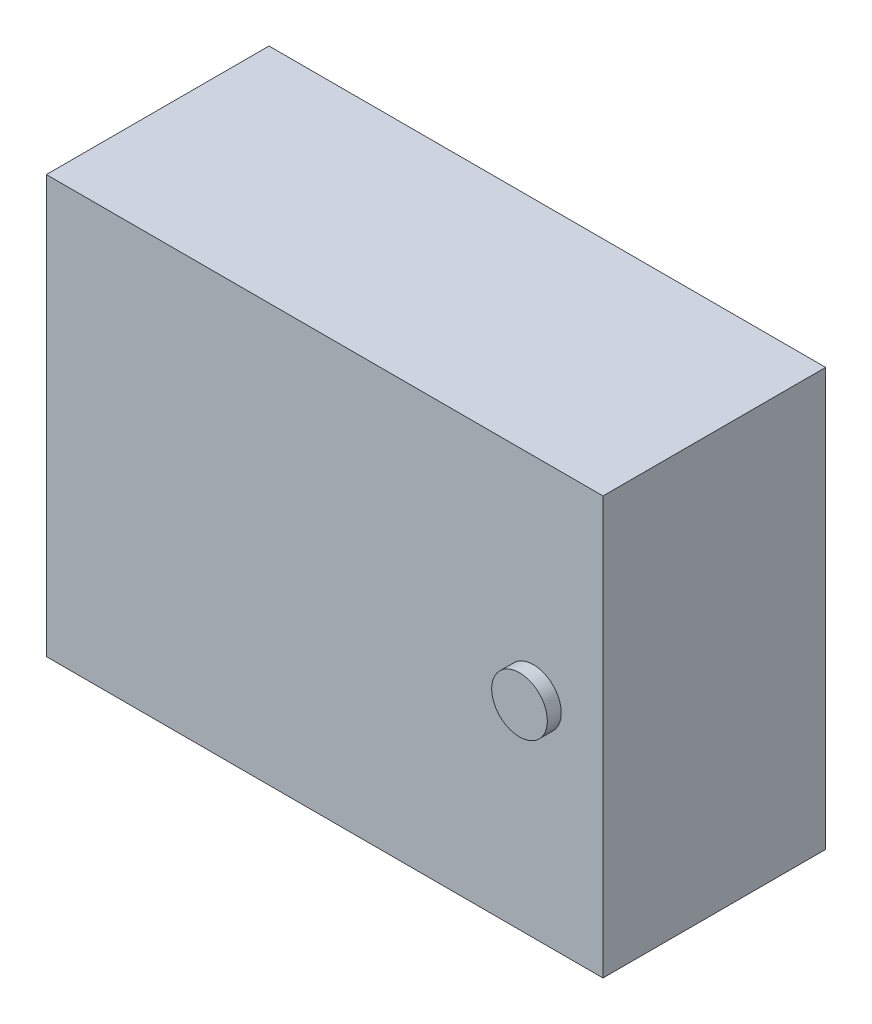
from build123d import *

# Parameters (mm, degrees)
SKETCH1_W           = 400
SKETCH1_H           = 300
BOSS_EXTRUDE1_DEPTH = 160
SKETCH2_R           = 20
BOSS_EXTRUDE2_DEPTH = 10


with BuildPart() as part:
    # Sketch1 → Boss-Extrude1 (new body)
    with BuildSketch(Plane.XY):
        Rectangle(SKETCH1_W, SKETCH1_H)
    extrude(amount=BOSS_EXTRUDE1_DEPTH)

    # Sketch2 → Boss-Extrude2 (add)
    with BuildSketch(Plane.XY.offset(160)):
        with Locations((150, 0)):
            Circle(SKETCH2_R)
    extrude(amount=BOSS_EXTRUDE2_DEPTH)


solid = part.part
